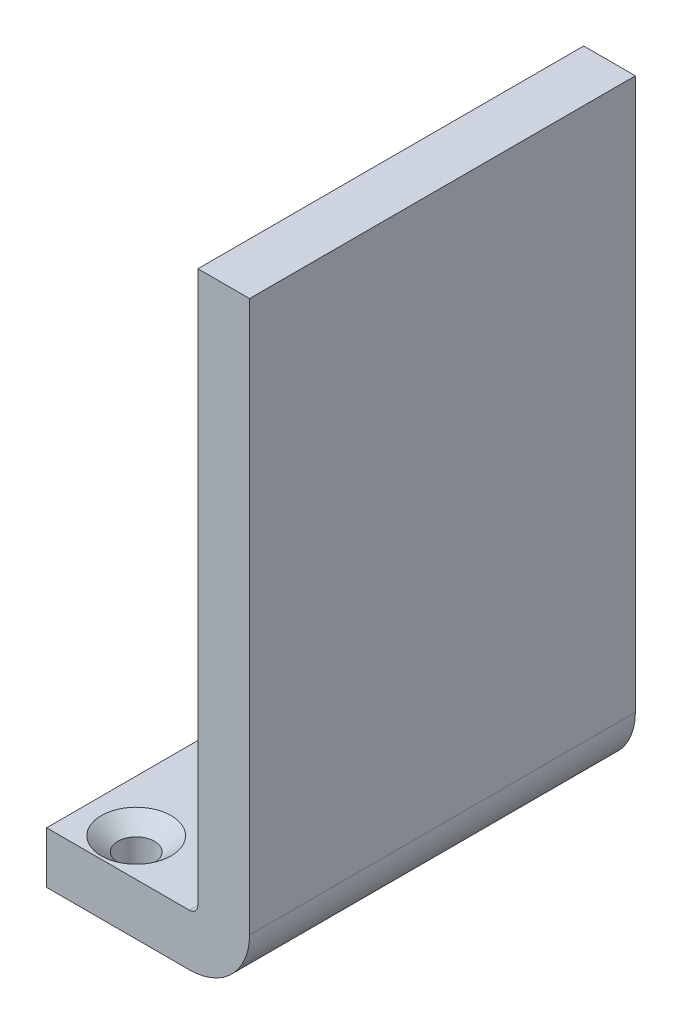
from build123d import *

# Parameters (mm, degrees)
SKETCH1_W                                           = 25.4
SKETCH1_H                                           = 71.12
BOSS_EXTRUDE1_DEPTH                                 = 9.525
CSK_FOR_1_4_FLAT_HEAD_MACHINE_SCREW_100_D           = 6.7564
CSK_FOR_1_4_FLAT_HEAD_MACHINE_SCREW_100_CSINK_D     = 12.8778
CSK_FOR_1_4_FLAT_HEAD_MACHINE_SCREW_100_CSINK_ANGLE = 100
SKETCH6_W                                           = 71.12
SKETCH6_H                                           = 9.525


with BuildPart() as part:
    # Sketch1 → Boss-Extrude1 (new body)
    with BuildSketch(Plane(origin=(0, 0, 0), x_dir=(1, 0, 0), z_dir=(0, 1, 0))):
        with Locations((12.7, 38.1)):
            Rectangle(SKETCH1_W, SKETCH1_H)
    extrude(amount=BOSS_EXTRUDE1_DEPTH)

    # CSK for 1/4 Flat Head Machine Screw (100)1 (through all)
    with Locations(Plane(origin=(0, 9.525, 0), x_dir=(1, 0, 0), z_dir=(0, 1, 0))):
        with Locations((9.525, 9.525), (9.525, 34.925), (9.525, 45.4406), (9.525, 66.3194)):
            CounterSinkHole(CSK_FOR_1_4_FLAT_HEAD_MACHINE_SCREW_100_D / 2, CSK_FOR_1_4_FLAT_HEAD_MACHINE_SCREW_100_CSINK_D / 2, counter_sink_angle=CSK_FOR_1_4_FLAT_HEAD_MACHINE_SCREW_100_CSINK_ANGLE)

    # Sweep1: sweep along a path in Sketch4
    with BuildLine(Plane(origin=(0, 0, -73.66), x_dir=(-1, 0, 0), z_dir=(0, 0, -1))) as sweep1_path:
        Line((-32.643415346, 112.7125), (-32.643415346, 11.1125))
        ThreePointArc((-32.643415346, 11.1125), (-30.783543406, 6.622371939), (-26.293415346, 4.7625))
        Line((-26.293415346, 4.7625), (-25.4, 4.7625))
    # Sketch6 → Sweep1 (sweep)
    with BuildSketch(Plane(origin=(25.4, 0, 0), x_dir=(0, 0, -1), z_dir=(1, 0, 0))):
        with Locations((38.1, 4.7625)):
            Rectangle(SKETCH6_W, SKETCH6_H)
    sweep(path=sweep1_path.line)


solid = part.part
